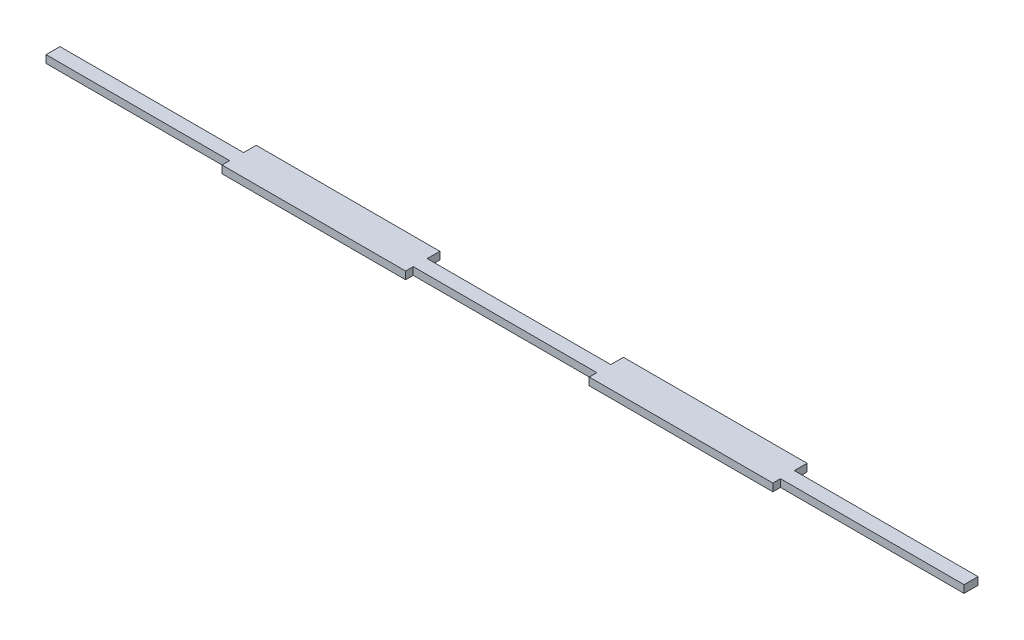
from build123d import *

# Parameters (mm, degrees)
BOSS_EXTRUDE1_DEPTH = 3


with BuildPart() as part:
    # Sketch1 → Boss-Extrude1 (new body)
    with BuildSketch(Plane(origin=(0, 0, 0), x_dir=(1, 0, 0), z_dir=(0, 1, 0))):
        Polygon((-181.15, 1.75), (-181.15, -3.75), (-108.69, -3.75), (-108.69, -6.75), (-36.23, -6.75), (-36.23, -3.75), (36.23, -3.75), (36.23, -6.75), (108.69, -6.75), (108.69, -3.75), (181.15, -3.75), (181.15, 1.75), (108.69, 1.75), (108.69, 6.75), (36.23, 6.75), (36.23, 1.75), (-36.23, 1.75), (-36.23, 6.75), (-108.69, 6.75), (-108.69, 1.75), align=None)
    extrude(amount=BOSS_EXTRUDE1_DEPTH)


solid = part.part
